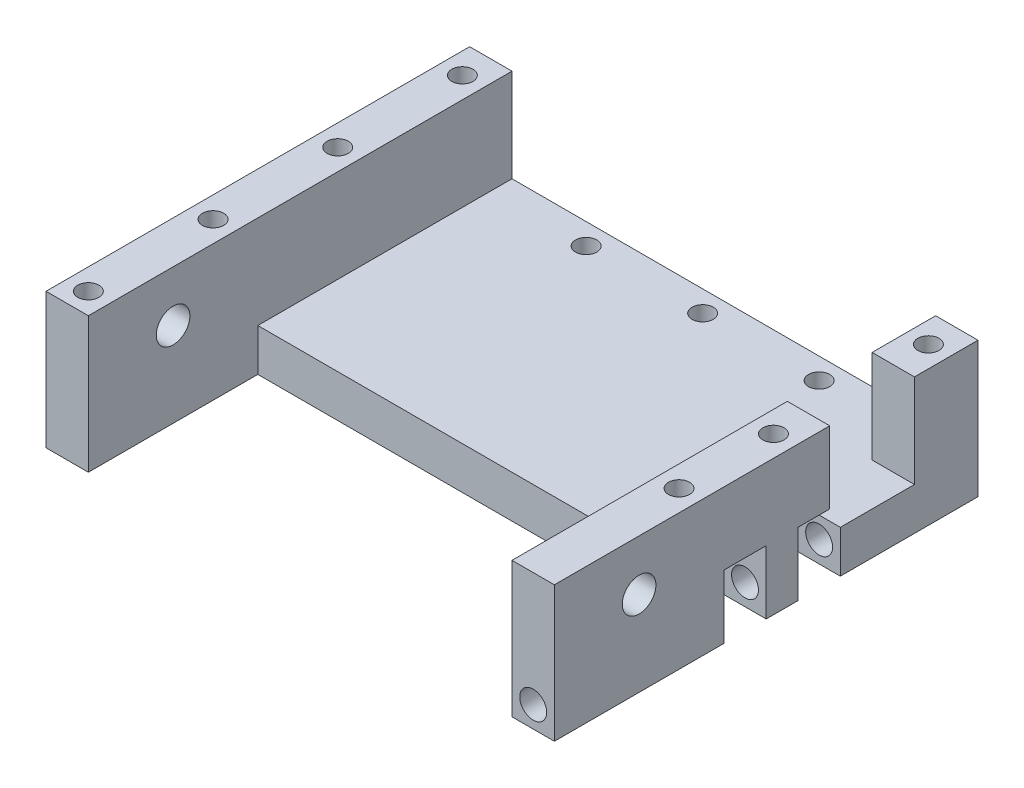
from build123d import *

# Parameters (mm, degrees)
BOSS_EXTRUDE3_DEPTH       = 50
SKETCH7_W                 = 100
SKETCH7_H                 = 40
CUT_EXTRUDE1_DEPTH        = 11
SKETCH8_R                 = 3.96875
CUT_EXTRUDE2_DEPTH        = 121
CUT_EXTRUDE3_REACH        = 122
SKETCH9_W                 = 20
SKETCH9_H                 = 22
SKETCH10_R                = 3.175
CUT_EXTRUDE4_DEPTH        = 80
SKETCH11_W                = 12.7
SKETCH11_H                = 10
CUT_EXTRUDE5_DEPTH        = 15
F_5_0MM_DOWEL_HOLE1_D     = 5
F_5_0MM_DOWEL_HOLE1_DEPTH = 25
F_5_0MM_DOWEL_HOLE1_TIP   = 1.502151548
SKETCH15_R                = 2.5
CUT_EXTRUDE6_DEPTH        = 15


with BuildPart() as part:
    # Sketch6 → Boss-Extrude3 (new body, symmetric)
    with BuildSketch(Plane.XY):
        Polygon((-60, 22), (-50, 22), (-50, 0), (50, 0), (50, 22), (60, 22), (60, -10), (-60, -10), align=None)
    extrude(amount=BOSS_EXTRUDE3_DEPTH, both=True)

    # Sketch7 → Cut-Extrude1 (cut, through all)
    with BuildSketch(Plane(origin=(0, 0, 0), x_dir=(1, 0, 0), z_dir=(0, 1, 0))):
        with Locations((0, -30)):
            Rectangle(SKETCH7_W, SKETCH7_H)
    extrude(amount=-CUT_EXTRUDE1_DEPTH, mode=Mode.SUBTRACT)

    # Sketch8 → Cut-Extrude2 (cut, through all)
    with BuildSketch(Plane(origin=(60, 0, 0), x_dir=(0, 0, -1), z_dir=(1, 0, 0))):
        with Locations((-30, 10)):
            Circle(SKETCH8_R)
    extrude(amount=-CUT_EXTRUDE2_DEPTH, mode=Mode.SUBTRACT)

    # Sketch9 → Cut-Extrude3 (cut, up to next)
    with BuildSketch(Plane(origin=(60, 0, 0), x_dir=(0, 0, -1), z_dir=(1, 0, 0)), mode=Mode.PRIVATE) as cut_extrude3_sk1:
        with Locations((25, 11)):
            Rectangle(SKETCH9_W, SKETCH9_H)
    cut_extrude3_tool1 = extrude(cut_extrude3_sk1.sketch, amount=-CUT_EXTRUDE3_REACH, mode=Mode.PRIVATE) & part.part
    add(cut_extrude3_tool1.solids().sort_by_distance((60, 11, -25))[0], mode=Mode.SUBTRACT)

    # Sketch10 → Cut-Extrude4 (cut)
    with BuildSketch(Plane.XY.offset(50)):
        with Locations((55, -5)):
            Circle(SKETCH10_R)
    extrude(amount=-CUT_EXTRUDE4_DEPTH, mode=Mode.SUBTRACT)

    # Sketch11 → Cut-Extrude5 (cut)
    with BuildSketch(Plane.XZ.offset(10)):
        with Locations((53.65, 5)):
            Rectangle(SKETCH11_W, SKETCH11_H)
        with Locations((53.65, -12.5)):
            Rectangle(SKETCH11_W, SKETCH11_H)
    extrude(amount=-CUT_EXTRUDE5_DEPTH, mode=Mode.SUBTRACT)

    # Ø5.0mm Dowel Hole1
    with Locations(Plane(origin=(-676.293536786, 42.00000002, -1303.282701689), x_dir=(1, 0, 0), z_dir=(0, 1, 0))):
        with Locations((731.293536786, -1318.853535022), (621.293536786, -1318.853535022), (621.293536786, -1348.282701689), (621.293536786, -1259.995201689), (731.293536786, -1259.995201689), (731.293536786, -1296.570201689), (621.293536786, -1289.424368355), (748.990363778, -1262.26989625)):
            Hole(F_5_0MM_DOWEL_HOLE1_D / 2, depth=F_5_0MM_DOWEL_HOLE1_DEPTH)
            with Locations((0, 0, -(F_5_0MM_DOWEL_HOLE1_DEPTH + F_5_0MM_DOWEL_HOLE1_TIP / 2))):  # 118° drill point
                Cone(0, F_5_0MM_DOWEL_HOLE1_D / 2, F_5_0MM_DOWEL_HOLE1_TIP, mode=Mode.SUBTRACT)

    # Sketch15 → Cut-Extrude6 (cut)
    with BuildSketch(Plane.XZ.offset(10)):
        with Locations((-55, -45)):
            Circle(SKETCH15_R)
        with Locations((-27.5, -45)):
            Circle(SKETCH15_R)
        with Locations((0, -45)):
            Circle(SKETCH15_R)
        with Locations((27.5, -45)):
            Circle(SKETCH15_R)
        with Locations((55, -45)):
            Circle(SKETCH15_R)
    extrude(amount=-CUT_EXTRUDE6_DEPTH, mode=Mode.SUBTRACT)


solid = part.part
